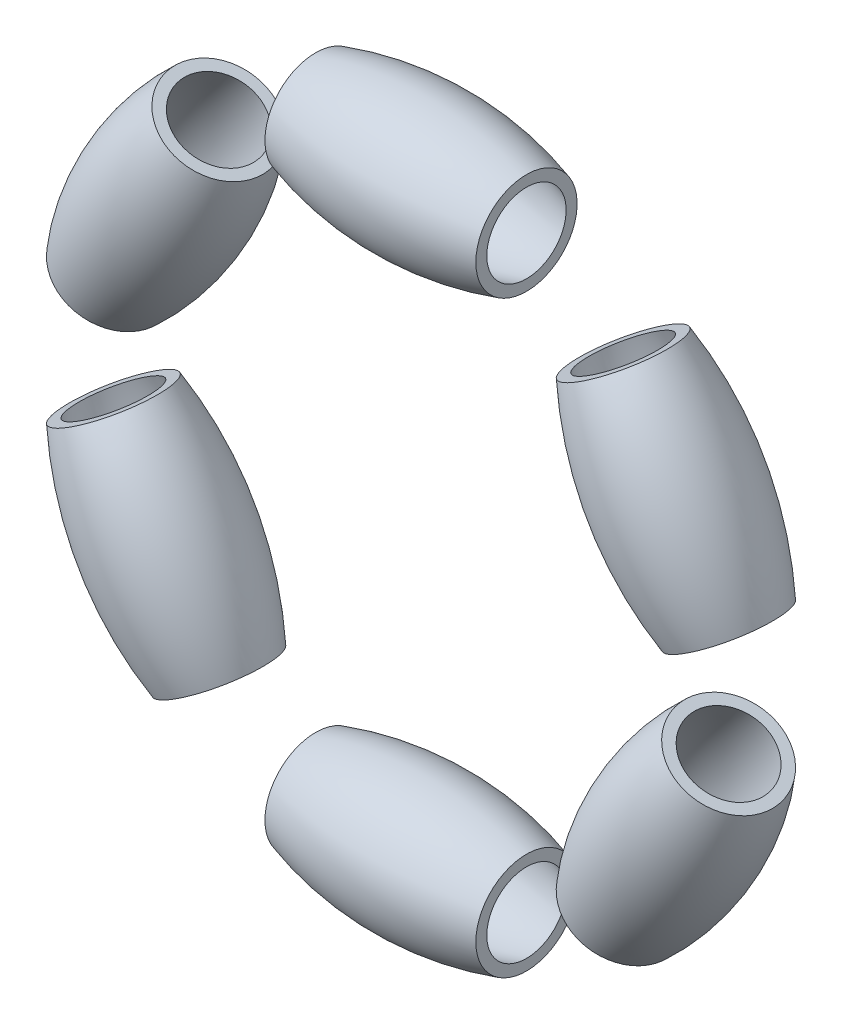
from build123d import *

# Parameters (mm, degrees)
CIRPATTERN1_COUNT = 6


with BuildPart() as part:
    # Sketch1 → Skin (revolve)
    with BuildSketch(Plane.XY):
        with BuildLine():
            Line((-20.173647626, 65.985028161), (-20.173647626, 63.890718743))
            ThreePointArc((-20.173647626, 63.890718743), (0, 67), (20.173647626, 63.890718743))
            Line((20.173647626, 63.890718743), (20.173647626, 65.985028161))
            ThreePointArc((20.173647626, 65.985028161), (0, 69), (-20.173647626, 65.985028161))
        make_face()
    revolve(axis=Axis((-20.173647626, 56.3, 0), (1, 0, 0)))


with BuildPart() as cirpattern1_1:
    # CirPattern1: pattern copy
    add(part.part.rotate(Axis((0, 0, 0), (0, 0, 1)), 1 * 360 / CIRPATTERN1_COUNT))


with BuildPart() as cirpattern1_2:
    # CirPattern1: pattern copy
    add(part.part.rotate(Axis((0, 0, 0), (0, 0, 1)), 2 * 360 / CIRPATTERN1_COUNT))


with BuildPart() as cirpattern1_3:
    # CirPattern1: pattern copy
    add(part.part.rotate(Axis((0, 0, 0), (0, 0, 1)), 3 * 360 / CIRPATTERN1_COUNT))


with BuildPart() as cirpattern1_4:
    # CirPattern1: pattern copy
    add(part.part.rotate(Axis((0, 0, 0), (0, 0, 1)), 4 * 360 / CIRPATTERN1_COUNT))


with BuildPart() as cirpattern1_5:
    # CirPattern1: pattern copy
    add(part.part.rotate(Axis((0, 0, 0), (0, 0, 1)), 5 * 360 / CIRPATTERN1_COUNT))


solid = Compound([part.part, cirpattern1_1.part, cirpattern1_2.part, cirpattern1_3.part, cirpattern1_4.part, cirpattern1_5.part])
